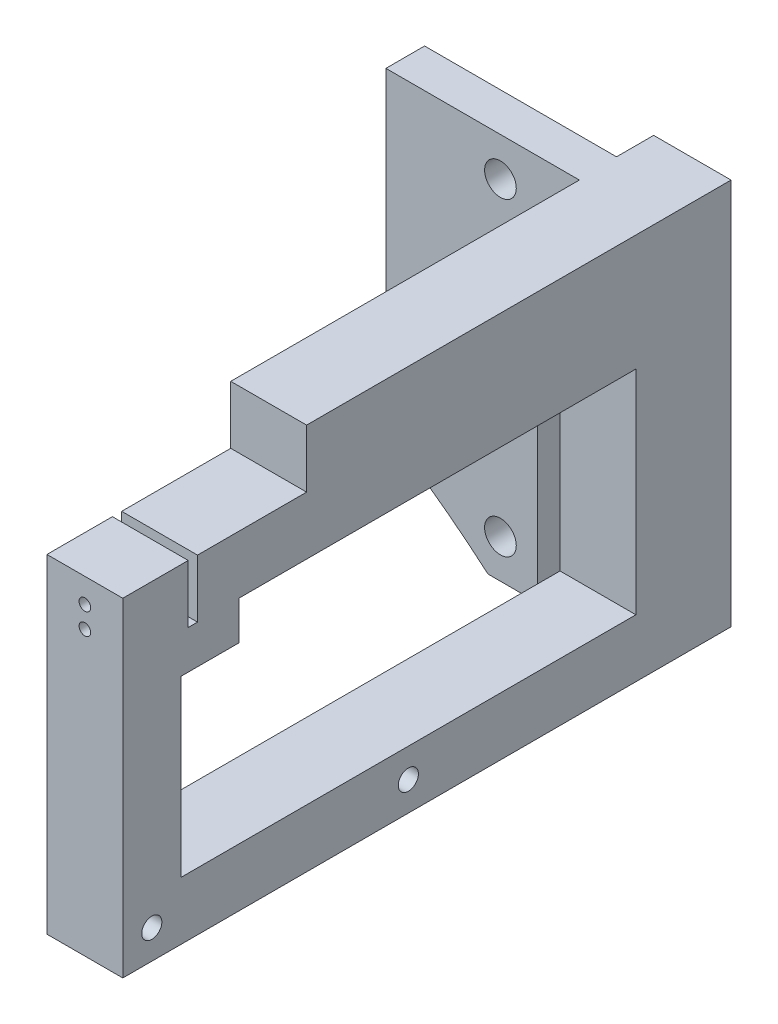
from build123d import *

# Parameters (mm, degrees)
SKETCH1_R                    = 2.600000007
BOSS_EXTRUDE1_DEPTH          = 6.35
BOSS_EXTRUDE2_DEPTH          = 12.446
SKETCH3_W                    = 74.675000002
SKETCH3_H                    = 34.925
BOSS_EXTRUDE4_DEPTH          = 12.446
SKETCH6_W                    = 12.446
SKETCH6_H                    = 57.212500002
BOSS_EXTRUDE5_DEPTH          = 9.525
SKETCH7_R                    = 1.650000002
CUT_EXTRUDE2_DEPTH           = 1
CUT_EXTRUDE2_DEPTH_BACK      = 45.196
SKETCH8_W                    = 9.525
SKETCH8_H                    = 6.35
BOSS_EXTRUDE6_DEPTH          = 12.446
SKETCH9_W                    = 1.524
SKETCH9_H                    = 9.525
CUT_EXTRUDE_THIN1_DEPTH      = 32.75
CUT_EXTRUDE_THIN1_DEPTH_BACK = 13.446
SKETCH10_R                   = 0.950000005
CUT_EXTRUDE3_DEPTH           = 12.262


with BuildPart() as part:
    # Sketch1 → Boss-Extrude1 (new body)
    with BuildSketch(Plane.XY):
        with BuildLine():
            Line((94.996, -31.75), (86.850341212, -31.75))
            ThreePointArc((86.850341212, -31.75), (78.719342976, -25.251372236), (70.104, -19.41004015))
            Line((70.104, -19.41004015), (70.104, -19.252396247))
            Line((70.104, -19.252396247), (70.104, 22.225))
            Line((70.104, 22.225), (70.104, 31.75))
            Line((70.104, 31.75), (101.6, 31.75))
            Line((101.6, 31.75), (101.6, 22.479))
            Line((101.6, 22.479), (94.996, 22.479))
            Line((94.996, 22.479), (94.996, -31.75))
        make_face()
        with Locations((88.9, -25.4)):
            Circle(SKETCH1_R, mode=Mode.SUBTRACT)
        with Locations((88.9, 25.4)):
            Circle(SKETCH1_R, mode=Mode.SUBTRACT)
    extrude(amount=BOSS_EXTRUDE1_DEPTH)

    # Sketch2 → Boss-Extrude2 (add)
    with BuildSketch(Plane.XY.offset(6.35)):
        Polygon((101.6, 22.479), (101.854, 22.479), (101.854, -31.75), (114.3, -31.75), (114.3, 31.75), (101.6, 31.75), align=None)
    extrude(amount=-BOSS_EXTRUDE2_DEPTH)

    # Sketch3 → Boss-Extrude4 (add)
    with BuildSketch(Plane(origin=(114.3, 0, 0), x_dir=(0, 0, -1), z_dir=(1, 0, 0))):
        Polygon((-6.35, -31.75), (-6.35, 22.225), (-87.375000002, 22.225), (-93.725000002, 22.225), (-93.725000002, -31.75), align=None)
        with Locations((-46.862500001, -4.7625)):
            Rectangle(SKETCH3_W, SKETCH3_H, mode=Mode.SUBTRACT)
    extrude(amount=-BOSS_EXTRUDE4_DEPTH)

    # Sketch6 → Boss-Extrude5 (add)
    with BuildSketch(Plane(origin=(0, 22.225, 0), x_dir=(1, 0, 0), z_dir=(0, 1, 0))):
        with Locations((108.077, -34.956250001)):
            Rectangle(SKETCH6_W, SKETCH6_H)
    extrude(amount=BOSS_EXTRUDE5_DEPTH)

    # Sketch7 → Cut-Extrude2 (cut, two sides)
    with BuildSketch(Plane(origin=(114.3, 0, 0), x_dir=(0, 0, -1), z_dir=(1, 0, 0))) as cut_extrude2_sk:
        with Locations((-88.962500002, -26.9875)):
            Circle(SKETCH7_R)
        with Locations((-46.862500001, -26.9875)):
            Circle(SKETCH7_R)
    extrude(amount=CUT_EXTRUDE2_DEPTH, mode=Mode.SUBTRACT)
    extrude(cut_extrude2_sk.sketch, amount=-CUT_EXTRUDE2_DEPTH_BACK, mode=Mode.SUBTRACT)

    # Sketch8 → Boss-Extrude6 (add)
    with BuildSketch(Plane(origin=(114.3, 0, 0), x_dir=(0, 0, -1), z_dir=(1, 0, 0))):
        with Locations((-79.437500002, 9.525)):
            Rectangle(SKETCH8_W, SKETCH8_H)
    extrude(amount=-BOSS_EXTRUDE6_DEPTH)

    # Sketch9 → Cut-Extrude-Thin1 (cut, two sides)
    with BuildSketch(Plane.ZY.offset(-101.854)) as cut_extrude_thin1_sk:
        with Locations((82.225000002, 17.4625)):
            Rectangle(SKETCH9_W, SKETCH9_H)
    extrude(amount=CUT_EXTRUDE_THIN1_DEPTH, mode=Mode.SUBTRACT)
    extrude(cut_extrude_thin1_sk.sketch, amount=-CUT_EXTRUDE_THIN1_DEPTH_BACK, mode=Mode.SUBTRACT)

    # Sketch10 → Cut-Extrude3 (cut)
    with BuildSketch(Plane.XY.offset(93.725000002)):
        with Locations((108.077, 14.700000064)):
            Circle(SKETCH10_R)
        with Locations((108.077, 18.224999872)):
            Circle(SKETCH10_R)
    extrude(amount=-CUT_EXTRUDE3_DEPTH, mode=Mode.SUBTRACT)


solid = part.part
